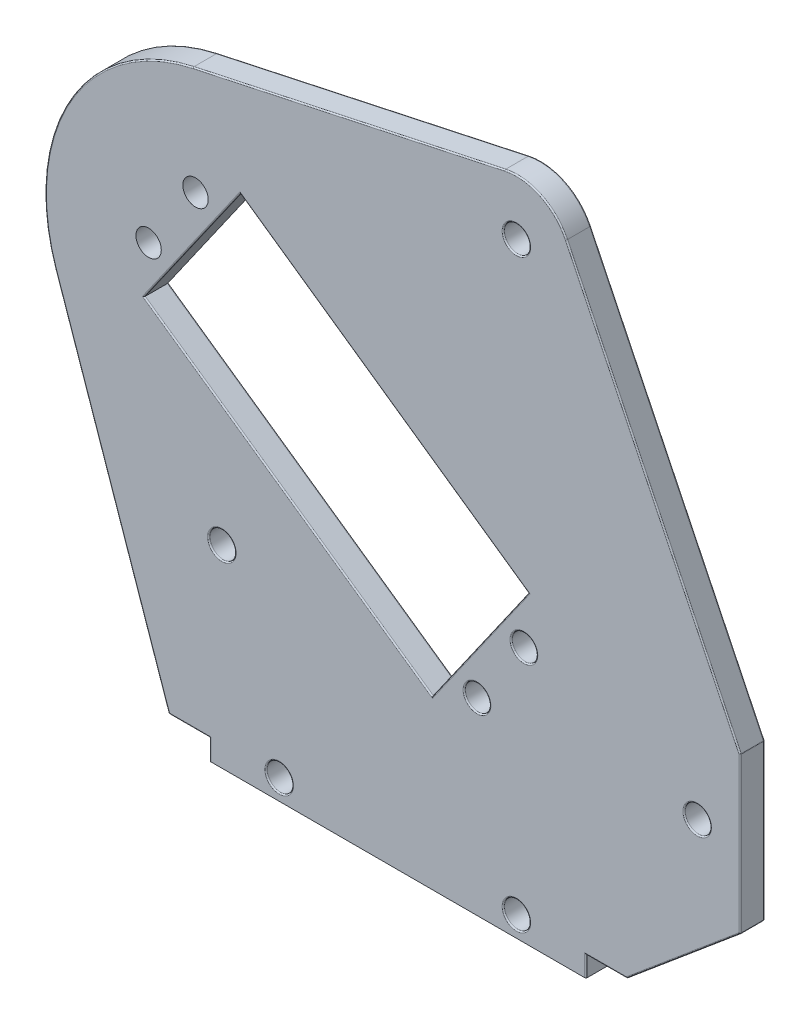
from build123d import *

# Parameters (mm, degrees)
SKETCH1_R            = 1.55
BOSS_EXTRUDE1_DEPTH  = 3
M3_CLEARANCE_HOLE1_D = 3.2
FILLET1_R            = 0.15
SKETCH13_W           = 46
SKETCH13_H           = 7.5
CUT_EXTRUDE1_DEPTH   = 4


with BuildPart() as part:
    # Sketch1 → Boss-Extrude1 (new body)
    with BuildSketch(Plane.XY):
        with BuildLine():
            Line((-25.029728066, 79.943634341), (13.072325527, 88.138211024))
            ThreePointArc((13.072325527, 88.138211024), (17.477220077, 87.602479874), (20.610605748, 84.460506273))
            Line((20.610605748, 84.460506273), (41.85, 40.621529892))
            Line((41.85, 40.621529892), (41.85, 21.621529892))
            Line((41.85, 21.621529892), (28, 10))
            Line((28, 10), (23, 10))
            Line((23, 10), (23, 0))
            Line((23, 0), (-23, 0))
            Line((-23, 0), (-23, 10))
            Line((-23, 10), (-28, 10))
            Line((-28, 10), (-41.843761624, 50.118193368))
            ThreePointArc((-41.843761624, 50.118193368), (-40.146654928, 68.813612437), (-25.029728066, 79.943634341))
        make_face()
        with Locations((9.67819959, 30.541182325)):
            Circle(SKETCH1_R, mode=Mode.SUBTRACT)
        with Locations((15.413963953, 38.732702767)):
            Circle(SKETCH1_R, mode=Mode.SUBTRACT)
        with Locations((-24.724486217, 66.837948149)):
            Circle(SKETCH1_R, mode=Mode.SUBTRACT)
        with Locations((-30.46025058, 58.646427706)):
            Circle(SKETCH1_R, mode=Mode.SUBTRACT)
        Polygon((-19.255753793, 69.417767072), (-31.014070738, 52.625150164), (4.209467166, 27.961363401), (15.967784111, 44.753980309), align=None, mode=Mode.SUBTRACT)
    extrude(amount=BOSS_EXTRUDE1_DEPTH)

    # M3 Clearance Hole1 (through all)
    with Locations(Plane(origin=(0, 0, 0), x_dir=(-1, 0, 0), z_dir=(0, 0, -1))):
        with Locations((-14.5, 81.5), (-36.6, 31.121529892), (-14.5, 10), (14.5, 10), (21.5, 31.121529892)):
            Hole(M3_CLEARANCE_HOLE1_D / 2)

    # Fillet1
    fillet1_edges = [part.edges().sort_by_distance(p)[0] for p in [
        (-5.978701269, 84.040922682, 0),
        (17.477220077, 87.602479874, 0),
        (-25.5, 10, 3),
        (31.230302874, 62.541018083, 0),
        (41.85, 31.121529892, 0),
        (34.925, 15.810764946, 0),
        (25.5, 10, 0),
        (23, 5, 0),
        (0, 0, 0),
        (-23, 5, 0),
        (-25.5, 10, 0),
        (-34.921880812, 30.059096684, 0),
        (-40.146654928, 68.813612437, 0),
        (-23, 5, 3),
        (0, 0, 3),
        (41.85, 40.621529892, 1.5),
        (41.85, 21.621529892, 1.5),
        (28, 10, 1.5),
        (23, 0, 1.5),
        (-23, 0, 1.5),
        (-28, 10, 1.5),
        (23, 5, 3),
        (25.5, 10, 3),
        (34.925, 15.810764946, 3),
        (-1.643984841, 57.085873691, 0),
        (-25.134912266, 61.021458618, 0),
        (-13.402301786, 40.293256783, 0),
        (10.088625639, 36.357671855, 0),
        (-1.643984841, 57.085873691, 3),
        (-25.134912266, 61.021458618, 3),
        (-13.402301786, 40.293256783, 3),
        (10.088625639, 36.357671855, 3),
        (41.85, 31.121529892, 3),
        (31.230302874, 62.541018083, 3),
        (13.863963953, 38.732702767, 0),
        (13.863963953, 38.732702767, 3),
        (17.477220077, 87.602479874, 3),
        (8.12819959, 30.541182325, 0),
        (8.12819959, 30.541182325, 3),
        (-5.978701269, 84.040922682, 3),
        (-40.146654928, 68.813612437, 3),
        (-23.1, 31.121529892, 0),
        (-23.1, 31.121529892, 3),
        (-16.1, 10, 0),
        (-16.1, 10, 3),
        (12.9, 10, 0),
        (12.9, 10, 3),
        (35, 31.121529892, 0),
        (35, 31.121529892, 3),
        (12.9, 81.5, 0),
        (12.9, 81.5, 3),
        (-34.921880812, 30.059096684, 3),
    ]]
    fillet(fillet1_edges, radius=FILLET1_R)

    # Sketch13 → Cut-Extrude1 (cut, through all)
    with BuildSketch(Plane.XY.offset(3)):
        with Locations((0, 3.75)):
            Rectangle(SKETCH13_W, SKETCH13_H)
    extrude(amount=-CUT_EXTRUDE1_DEPTH, mode=Mode.SUBTRACT)


solid = part.part
